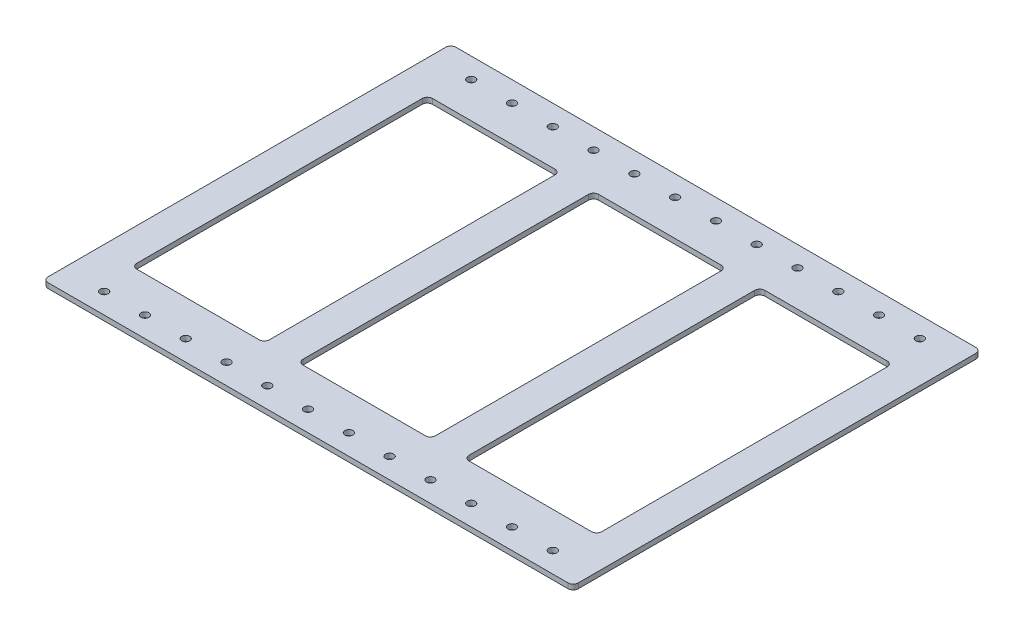
from build123d import *

# Parameters (mm, degrees)
SKETCH1_W                  = 330.2
SKETCH1_H                  = 254
SKETCH1_W_2                = 82.55
SKETCH1_H_2                = 184.15
BOSS_EXTRUDE1_DEPTH        = 3.175
FILLET1_R                  = 3.175
F_9_0_196_DIAMETER_HOLE1_D = 4.9784
LPATTERN1_COUNT            = 12
LPATTERN1_PITCH            = 25.4


with BuildPart() as part:
    # Sketch1 → Boss-Extrude1 (new body)
    with BuildSketch(Plane(origin=(0, 0, 0), x_dir=(1, 0, 0), z_dir=(0, 1, 0))):
        Rectangle(SKETCH1_W, SKETCH1_H)
        with Locations((-103.505, 0)):
            Rectangle(SKETCH1_W_2, SKETCH1_H_2, mode=Mode.SUBTRACT)
        Rectangle(SKETCH1_W_2, SKETCH1_H_2, mode=Mode.SUBTRACT)
        with Locations((103.505, 0)):
            Rectangle(SKETCH1_W_2, SKETCH1_H_2, mode=Mode.SUBTRACT)
    extrude(amount=BOSS_EXTRUDE1_DEPTH)

    # Fillet1
    fillet1_edges = [part.edges().sort_by_distance(p)[0] for p in [
        (-144.78, 1.5875, -92.075),
        (-144.78, 1.5875, 92.075),
        (-62.23, 1.5875, 92.075),
        (-62.23, 1.5875, -92.075),
        (-41.275, 1.5875, -92.075),
        (-41.275, 1.5875, 92.075),
        (41.275, 1.5875, 92.075),
        (41.275, 1.5875, -92.075),
        (62.23, 1.5875, -92.075),
        (62.23, 1.5875, 92.075),
        (144.78, 1.5875, 92.075),
        (144.78, 1.5875, -92.075),
        (-165.1, 1.5875, -127),
        (165.1, 1.5875, -127),
        (165.1, 1.5875, 127),
        (-165.1, 1.5875, 127),
    ]]
    fillet(fillet1_edges, radius=FILLET1_R)

    # #9 (0.196) Diameter Hole1 (through all)
    with Locations(Plane(origin=(-139.7, 3.175, 114.3), x_dir=(0, 0, 1), z_dir=(0, 1, 0))):
        with Locations((0, 0), (-228.6, 0)):
            f_9_0_196_diameter_hole1 = Hole(F_9_0_196_DIAMETER_HOLE1_D / 2)

    # LPattern1: #9 (0.196) Diameter Hole1 ×12
    with Locations(*[(i * LPATTERN1_PITCH, 0, 0) for i in range(1, LPATTERN1_COUNT)]):
        add(f_9_0_196_diameter_hole1, mode=Mode.SUBTRACT)


solid = part.part
